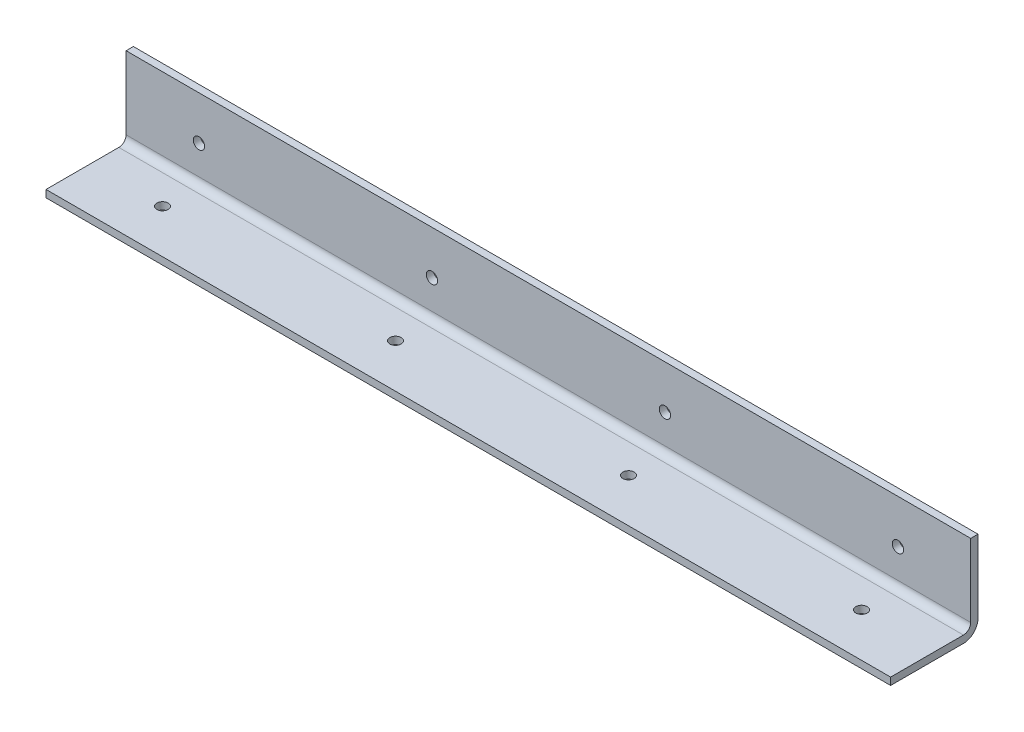
from build123d import *

# Parameters (mm, degrees)
BOSS_EXTRUDE1_DEPTH = 184.15
FILLET1_R           = 3.175
FILLET2_R           = 6.35
SKETCH2_R           = 2.4638
CUT_EXTRUDE1_DEPTH  = 39.1
SKETCH3_R           = 2.4638
CUT_EXTRUDE2_DEPTH  = 39.1
LPATTERN1_COUNT     = 4
LPATTERN1_PITCH     = 101.6


with BuildPart() as part:
    # Sketch1 → Boss-Extrude1 (new body, symmetric)
    with BuildSketch(Plane(origin=(0, 0, 0), x_dir=(0, 0, -1), z_dir=(1, 0, 0))):
        Polygon((0, 38.1), (0, 0), (-38.1, 0), (-38.1, 3.175), (-3.175, 3.175), (-3.175, 38.1), align=None)
    extrude(amount=BOSS_EXTRUDE1_DEPTH, both=True)

    # Fillet1
    fillet1_edges = [part.edges().sort_by_distance(p)[0] for p in [
        (0, 3.175, 3.175),
    ]]
    fillet(fillet1_edges, radius=FILLET1_R)

    # Fillet2
    fillet2_edges = [part.edges().sort_by_distance(p)[0] for p in [
        (0, 0, 0),
    ]]
    fillet(fillet2_edges, radius=FILLET2_R)

    # Sketch2 → Cut-Extrude1 (cut, through all)
    with BuildSketch(Plane(origin=(0, 0, 0), x_dir=(-1, 0, 0), z_dir=(0, 0, -1))):
        with Locations((152.4, 19.05)):
            Circle(SKETCH2_R)
    cut_extrude1 = extrude(amount=-CUT_EXTRUDE1_DEPTH, mode=Mode.SUBTRACT)

    # Sketch3 → Cut-Extrude2 (cut, through all)
    with BuildSketch(Plane.XZ):
        with Locations((-152.4, 19.05)):
            Circle(SKETCH3_R)
    cut_extrude2 = extrude(amount=-CUT_EXTRUDE2_DEPTH, mode=Mode.SUBTRACT)

    # LPattern1: Cut-Extrude1, Cut-Extrude2 ×4
    with Locations(*[(i * LPATTERN1_PITCH, 0, 0) for i in range(1, LPATTERN1_COUNT)]):
        add(cut_extrude1, mode=Mode.SUBTRACT)
        add(cut_extrude2, mode=Mode.SUBTRACT)


solid = part.part
